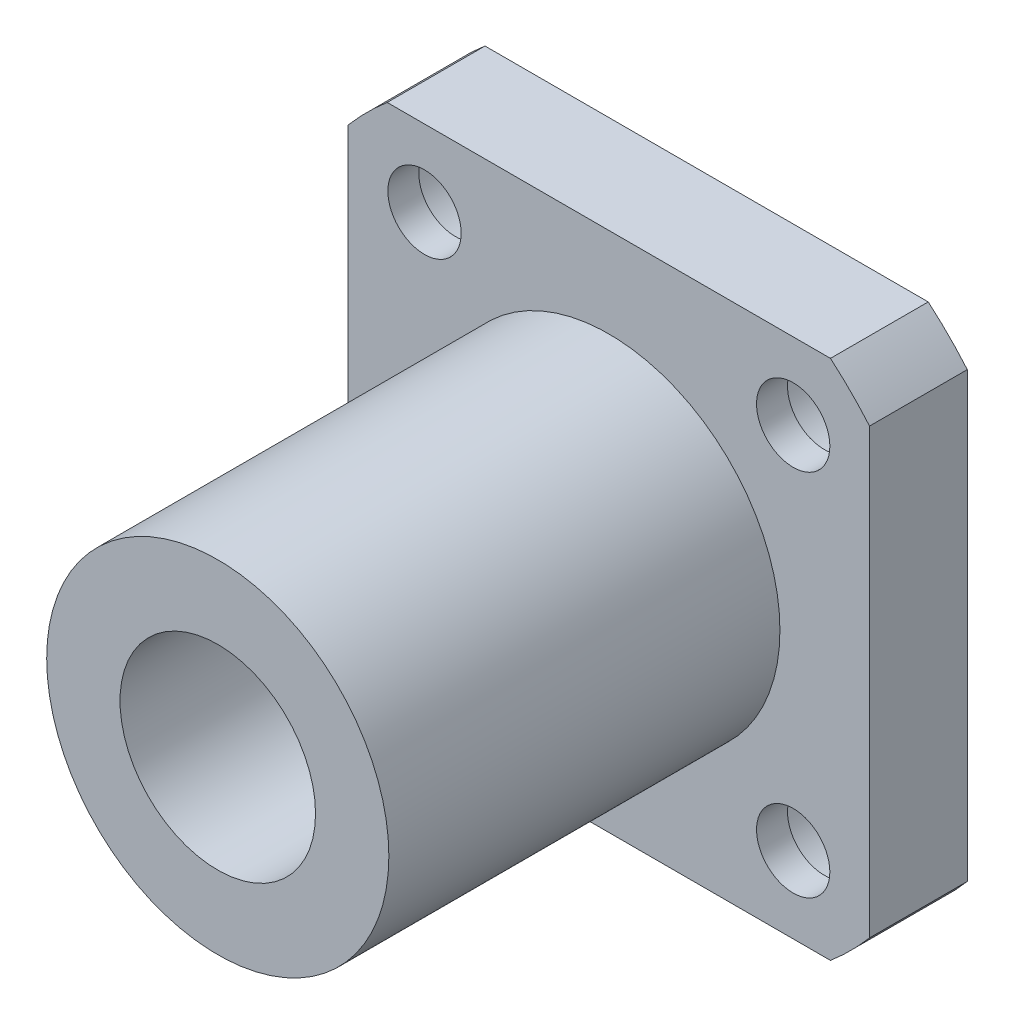
from build123d import *

# Parameters (mm, degrees)
EXTRUDE_1_DEPTH     = 6
SKETCH_2_R          = 10.5
EXTRUDE_2_DEPTH     = 24
SKETCH_3_R          = 6
CUT_EXTRUDE_1_DEPTH = 30
CUT_EXTRUDE_2_DEPTH = 1.9
SKETCH_5_R          = 3.75
CUT_EXTRUDE_3_DEPTH = 4.1


with BuildPart() as part:
    # 草图1 → 凸台-拉伸1 (new body)
    with BuildSketch(Plane.XY):
        with BuildLine():
            Line((-13.601470509, 16), (13.601470509, 16))
            ThreePointArc((13.601470509, 16), (14.849242405, 14.849242405), (16, 13.601470509))
            Line((16, 13.601470509), (16, -13.601470509))
            ThreePointArc((16, -13.601470509), (14.849242405, -14.849242405), (13.601470509, -16))
            Line((13.601470509, -16), (-13.601470509, -16))
            ThreePointArc((-13.601470509, -16), (-14.849242405, -14.849242405), (-16, -13.601470509))
            Line((-16, -13.601470509), (-16, 13.601470509))
            ThreePointArc((-16, 13.601470509), (-14.849242405, 14.849242405), (-13.601470509, 16))
        make_face()
    extrude(amount=EXTRUDE_1_DEPTH)

    # 草图2 → 凸台-拉伸2 (add)
    with BuildSketch(Plane.XY.offset(6)):
        Circle(SKETCH_2_R)
    extrude(amount=EXTRUDE_2_DEPTH)

    # 草图3 → 切除-拉伸1 (cut)
    with BuildSketch(Plane.XY.offset(30)):
        Circle(SKETCH_3_R)
    extrude(amount=-CUT_EXTRUDE_1_DEPTH, mode=Mode.SUBTRACT)

    # 草图4 → 切除-拉伸2 (cut)
    with BuildSketch(Plane.XY.offset(6)):
        with BuildLine():
            ThreePointArc((-12.788894575, 9.614789418), (-11.234557947, 9.06510111), (-9.722718241, 9.722718241))
            Line((-9.722718241, 9.722718241), (-11.313708499, 11.313708499))
            ThreePointArc((-11.313708499, 11.313708499), (-12.081202351, 10.490212093), (-12.788894575, 9.614789418))
        make_face()
        with BuildLine():
            Line((-11.313708499, 11.313708499), (-9.722718241, 9.722718241))
            ThreePointArc((-9.722718241, 9.722718241), (-9.234979551, 10.452670776), (-9.063708499, 11.313708499))
            ThreePointArc((-9.063708499, 11.313708499), (-9.205976551, 12.101087718), (-9.614789418, 12.788894575))
            ThreePointArc((-9.614789418, 12.788894575), (-10.490212093, 12.081202351), (-11.313708499, 11.313708499))
        make_face()
        with BuildLine():
            ThreePointArc((-12.788894575, 9.614789418), (-12.081202351, 10.490212093), (-11.313708499, 11.313708499))
            Line((-11.313708499, 11.313708499), (-12.904698757, 12.904698757))
            ThreePointArc((-12.904698757, 12.904698757), (-13.562315888, 11.234557947), (-12.788894575, 9.614789418))
        make_face()
        with BuildLine():
            Line((-12.904698757, 12.904698757), (-11.313708499, 11.313708499))
            ThreePointArc((-11.313708499, 11.313708499), (-10.490212093, 12.081202351), (-9.614789418, 12.788894575))
            ThreePointArc((-9.614789418, 12.788894575), (-11.234557947, 13.562315888), (-12.904698757, 12.904698757))
        make_face()
        with BuildLine():
            ThreePointArc((9.614789418, 12.788894575), (9.06510111, 11.234557947), (9.722718241, 9.722718241))
            Line((9.722718241, 9.722718241), (11.313708499, 11.313708499))
            ThreePointArc((11.313708499, 11.313708499), (10.490212093, 12.081202351), (9.614789418, 12.788894575))
        make_face()
        with BuildLine():
            Line((11.313708499, 11.313708499), (9.722718241, 9.722718241))
            ThreePointArc((9.722718241, 9.722718241), (11.234557947, 9.06510111), (12.788894575, 9.614789418))
            ThreePointArc((12.788894575, 9.614789418), (12.081202351, 10.490212093), (11.313708499, 11.313708499))
        make_face()
        with BuildLine():
            ThreePointArc((9.614789418, 12.788894575), (10.490212093, 12.081202351), (11.313708499, 11.313708499))
            Line((11.313708499, 11.313708499), (12.904698757, 12.904698757))
            ThreePointArc((12.904698757, 12.904698757), (11.234557947, 13.562315888), (9.614789418, 12.788894575))
        make_face()
        with BuildLine():
            Line((12.904698757, 12.904698757), (11.313708499, 11.313708499))
            ThreePointArc((11.313708499, 11.313708499), (12.081202351, 10.490212093), (12.788894575, 9.614789418))
            ThreePointArc((12.788894575, 9.614789418), (13.360861238, 10.380078131), (13.563708499, 11.313708499))
            ThreePointArc((13.563708499, 11.313708499), (13.392437447, 12.174746222), (12.904698757, 12.904698757))
        make_face()
        with BuildLine():
            ThreePointArc((12.788894575, -9.614789418), (11.234557947, -9.06510111), (9.722718241, -9.722718241))
            Line((9.722718241, -9.722718241), (11.313708499, -11.313708499))
            ThreePointArc((11.313708499, -11.313708499), (12.081202351, -10.490212093), (12.788894575, -9.614789418))
        make_face()
        with BuildLine():
            Line((11.313708499, -11.313708499), (9.722718241, -9.722718241))
            ThreePointArc((9.722718241, -9.722718241), (9.06510111, -11.234557947), (9.614789418, -12.788894575))
            ThreePointArc((9.614789418, -12.788894575), (10.490212093, -12.081202351), (11.313708499, -11.313708499))
        make_face()
        with BuildLine():
            ThreePointArc((12.788894575, -9.614789418), (12.081202351, -10.490212093), (11.313708499, -11.313708499))
            Line((11.313708499, -11.313708499), (12.904698757, -12.904698757))
            ThreePointArc((12.904698757, -12.904698757), (13.392437447, -12.174746222), (13.563708499, -11.313708499))
            ThreePointArc((13.563708499, -11.313708499), (13.360861238, -10.380078131), (12.788894575, -9.614789418))
        make_face()
        with BuildLine():
            Line((12.904698757, -12.904698757), (11.313708499, -11.313708499))
            ThreePointArc((11.313708499, -11.313708499), (10.490212093, -12.081202351), (9.614789418, -12.788894575))
            ThreePointArc((9.614789418, -12.788894575), (11.234557947, -13.562315888), (12.904698757, -12.904698757))
        make_face()
        with BuildLine():
            ThreePointArc((-9.063708499, -11.313708499), (-9.234979551, -10.452670776), (-9.722718241, -9.722718241))
            Line((-9.722718241, -9.722718241), (-11.313708499, -11.313708499))
            ThreePointArc((-11.313708499, -11.313708499), (-10.490212093, -12.081202351), (-9.614789418, -12.788894575))
            ThreePointArc((-9.614789418, -12.788894575), (-9.205976551, -12.101087718), (-9.063708499, -11.313708499))
        make_face()
        with BuildLine():
            Line((-11.313708499, -11.313708499), (-9.722718241, -9.722718241))
            ThreePointArc((-9.722718241, -9.722718241), (-11.234557947, -9.06510111), (-12.788894575, -9.614789418))
            ThreePointArc((-12.788894575, -9.614789418), (-12.081202351, -10.490212093), (-11.313708499, -11.313708499))
        make_face()
        with BuildLine():
            ThreePointArc((-9.614789418, -12.788894575), (-10.490212093, -12.081202351), (-11.313708499, -11.313708499))
            Line((-11.313708499, -11.313708499), (-12.904698757, -12.904698757))
            ThreePointArc((-12.904698757, -12.904698757), (-11.234557947, -13.562315888), (-9.614789418, -12.788894575))
        make_face()
        with BuildLine():
            Line((-12.904698757, -12.904698757), (-11.313708499, -11.313708499))
            ThreePointArc((-11.313708499, -11.313708499), (-12.081202351, -10.490212093), (-12.788894575, -9.614789418))
            ThreePointArc((-12.788894575, -9.614789418), (-13.562315888, -11.234557947), (-12.904698757, -12.904698757))
        make_face()
    extrude(amount=-CUT_EXTRUDE_2_DEPTH, mode=Mode.SUBTRACT)

    # 草图5 → 切除-拉伸3 (cut)
    with BuildSketch(Plane.XY.offset(4.1)):
        with Locations((-11.313708499, 11.313708499)):
            Circle(SKETCH_5_R)
        with Locations((11.313708499, 11.313708499)):
            Circle(SKETCH_5_R)
        with Locations((11.313708499, -11.313708499)):
            Circle(SKETCH_5_R)
        with Locations((-11.313708499, -11.313708499)):
            Circle(SKETCH_5_R)
    extrude(amount=-CUT_EXTRUDE_3_DEPTH, mode=Mode.SUBTRACT)


solid = part.part
